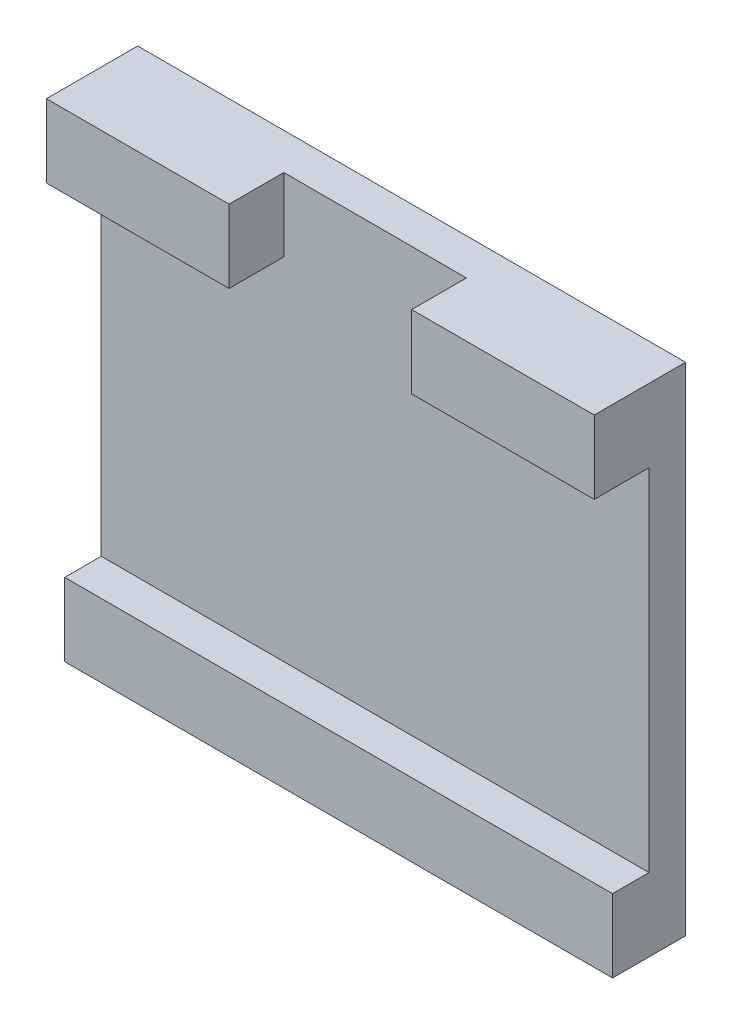
from build123d import *

# Parameters (mm, degrees)
SKETCH1_W           = 30
SKETCH1_H           = 27.2
BOSS_EXTRUDE1_DEPTH = 2
SKETCH1_4_W         = 30
SKETCH1_4_H         = 4
BOSS_EXTRUDE2_DEPTH = 2
SKETCH1_5_W         = 30
SKETCH1_5_H         = 4
BOSS_EXTRUDE3_DEPTH = 3
CUT_EXTRUDE1_REACH  = 29.789
SKETCH3_W           = 10
SKETCH3_H           = 3


with BuildPart() as part:
    # Sketch1 → Boss-Extrude1 (new body)
    with BuildSketch(Plane.XY):
        with Locations((0, 13.6)):
            Rectangle(SKETCH1_W, SKETCH1_H)
    extrude(amount=-BOSS_EXTRUDE1_DEPTH)

    # Sketch1_4 → Boss-Extrude2 (add)
    with BuildSketch(Plane.XY):
        with Locations((0, 2)):
            Rectangle(SKETCH1_4_W, SKETCH1_4_H)
    extrude(amount=BOSS_EXTRUDE2_DEPTH)

    # Sketch1_5 → Boss-Extrude3 (add)
    with BuildSketch(Plane.XY):
        with Locations((0, 25.2)):
            Rectangle(SKETCH1_5_W, SKETCH1_5_H)
    extrude(amount=BOSS_EXTRUDE3_DEPTH)

    # Sketch3 → Cut-Extrude1 (cut, up to next)
    with BuildSketch(Plane.XZ.offset(-23.2), mode=Mode.PRIVATE) as cut_extrude1_sk1:
        with Locations((0, 1.5)):
            Rectangle(SKETCH3_W, SKETCH3_H)
    cut_extrude1_tool1 = extrude(cut_extrude1_sk1.sketch, amount=-CUT_EXTRUDE1_REACH, mode=Mode.PRIVATE) & part.part
    add(cut_extrude1_tool1.solids().sort_by_distance((0, 23.2, 1.5))[0], mode=Mode.SUBTRACT)


solid = part.part
